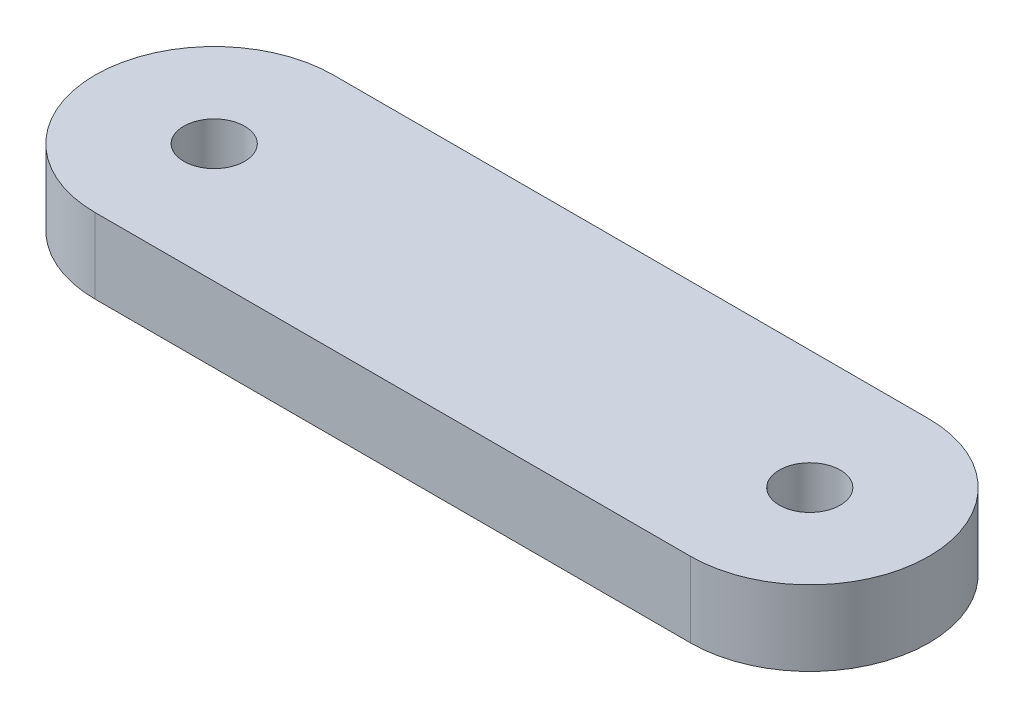
from build123d import *

# Parameters (mm, degrees)
SKETCH1_R           = 1.625
BOSS_EXTRUDE1_DEPTH = 4


with BuildPart() as part:
    # Sketch1 → Boss-Extrude1 (new body)
    with BuildSketch(Plane(origin=(0, 0, 0), x_dir=(1, 0, 0), z_dir=(0, 1, 0))):
        with BuildLine():
            Line((-18.618446602, -6.35), (13.131553398, -6.35))
            ThreePointArc((13.131553398, -6.35), (19.481553398, 0), (13.131553398, 6.35))
            Line((13.131553398, 6.35), (-18.618446602, 6.35))
            ThreePointArc((-18.618446602, 6.35), (-24.968446602, 0), (-18.618446602, -6.35))
        make_face()
        with Locations((-18.618446602, 0)):
            Circle(SKETCH1_R, mode=Mode.SUBTRACT)
        with Locations((13.131553398, 0)):
            Circle(SKETCH1_R, mode=Mode.SUBTRACT)
    extrude(amount=BOSS_EXTRUDE1_DEPTH)


solid = part.part
